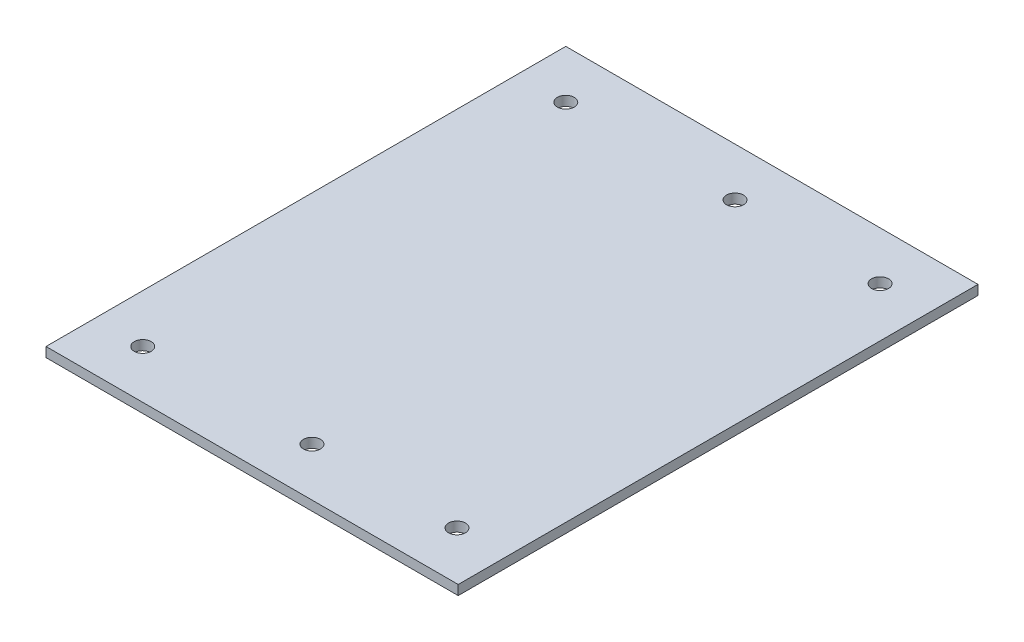
from build123d import *

# Parameters (mm, degrees)
SKETCH1_W           = 170.5
SKETCH1_H           = 215
SKETCH1_R           = 3.5
BOSS_EXTRUDE1_DEPTH = 4


with BuildPart() as part:
    # Sketch1 → Boss-Extrude1 (new body)
    with BuildSketch(Plane(origin=(0, 0, 0), x_dir=(1, 0, 0), z_dir=(0, 1, 0))):
        with Locations((85.25, 97.5)):
            Rectangle(SKETCH1_W, SKETCH1_H)
        with Locations((20, 10)):
            Circle(SKETCH1_R, mode=Mode.SUBTRACT)
        with Locations((150, 10)):
            Circle(SKETCH1_R, mode=Mode.SUBTRACT)
        with Locations((90, 10)):
            Circle(SKETCH1_R, mode=Mode.SUBTRACT)
        with Locations((20, 185)):
            Circle(SKETCH1_R, mode=Mode.SUBTRACT)
        with Locations((90, 185)):
            Circle(SKETCH1_R, mode=Mode.SUBTRACT)
        with Locations((150, 185)):
            Circle(SKETCH1_R, mode=Mode.SUBTRACT)
    extrude(amount=BOSS_EXTRUDE1_DEPTH)


solid = part.part
